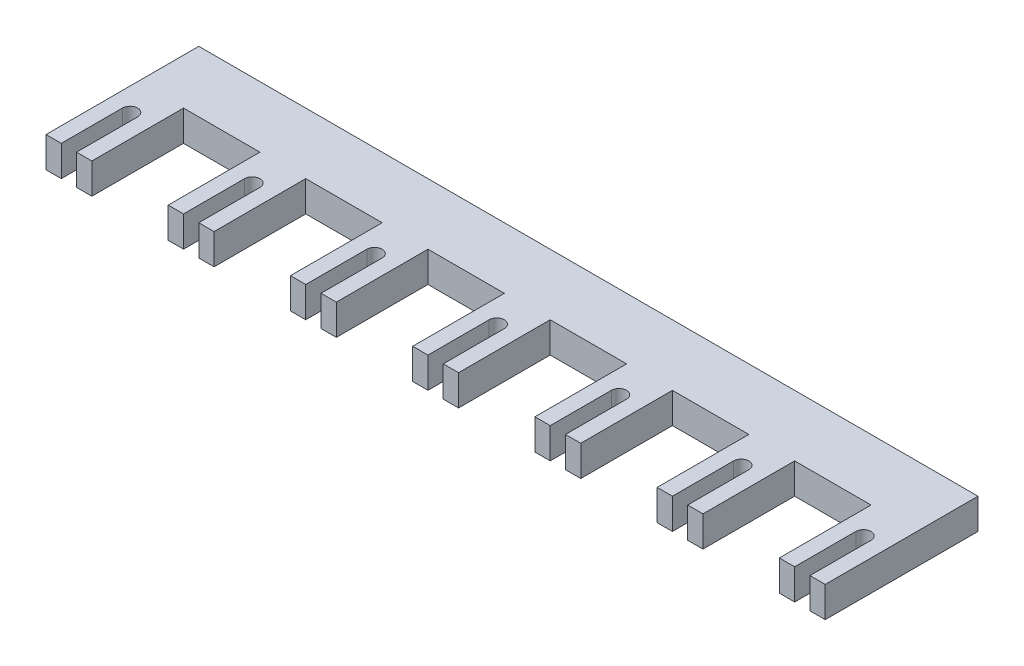
from build123d import *

# Parameters (mm, degrees)
BOSS_EXTRUDE1_DEPTH = 10


with BuildPart() as part:
    # Sketch1 → Boss-Extrude1 (new body)
    with BuildSketch(Plane(origin=(0, 0, 0), x_dir=(1, 0, 0), z_dir=(0, 1, 0))):
        with BuildLine():
            Line((0, 0), (0, 20))
            ThreePointArc((0, 20), (2.5, 22.5), (5, 20))
            Line((5, 20), (5, 0))
            Line((5, 0), (10, 0))
            Line((10, 0), (10, 30))
            Line((10, 30), (35, 30))
            Line((35, 30), (35, 0))
            Line((35, 0), (40, 0))
            Line((40, 0), (40, 20))
            ThreePointArc((40, 20), (42.5, 22.5), (45, 20))
            Line((45, 20), (45, 0))
            Line((45, 0), (50, 0))
            Line((50, 0), (50, 30))
            Line((50, 30), (75, 30))
            Line((75, 30), (75, 0))
            Line((75, 0), (80, 0))
            Line((80, 0), (80, 20))
            ThreePointArc((80, 20), (82.5, 22.5), (85, 20))
            Line((85, 20), (85, 0))
            Line((85, 0), (90, 0))
            Line((90, 0), (90, 30))
            Line((90, 30), (115, 30))
            Line((115, 30), (115, 0))
            Line((115, 0), (120, 0))
            Line((120, 0), (120, 20))
            ThreePointArc((120, 20), (122.5, 22.5), (125, 20))
            Line((125, 20), (125, 0))
            Line((125, 0), (130, 0))
            Line((130, 0), (130, 30))
            Line((130, 30), (155, 30))
            Line((155, 30), (155, 0))
            Line((155, 0), (160, 0))
            Line((160, 0), (160, 20))
            ThreePointArc((160, 20), (162.5, 22.5), (165, 20))
            Line((165, 20), (165, 0))
            Line((165, 0), (170, 0))
            Line((170, 0), (170, 30))
            Line((170, 30), (195, 30))
            Line((195, 30), (195, 0))
            Line((195, 0), (200, 0))
            Line((200, 0), (200, 20))
            ThreePointArc((200, 20), (202.5, 22.5), (205, 20))
            Line((205, 20), (205, 0))
            Line((205, 0), (210, 0))
            Line((210, 0), (210, 30))
            Line((210, 30), (235, 30))
            Line((235, 30), (235, 0))
            Line((235, 0), (240, 0))
            Line((240, 0), (240, 20))
            ThreePointArc((240, 20), (242.5, 22.5), (245, 20))
            Line((245, 20), (245, 0))
            Line((245, 0), (250, 0))
            Line((250, 0), (250, 30))
            Line((250, 30), (250, 50))
            Line((250, 50), (-5, 50))
            Line((-5, 50), (-5, 30))
            Line((-5, 30), (-5, 0))
            Line((-5, 0), (0, 0))
        make_face()
    extrude(amount=BOSS_EXTRUDE1_DEPTH)


solid = part.part
